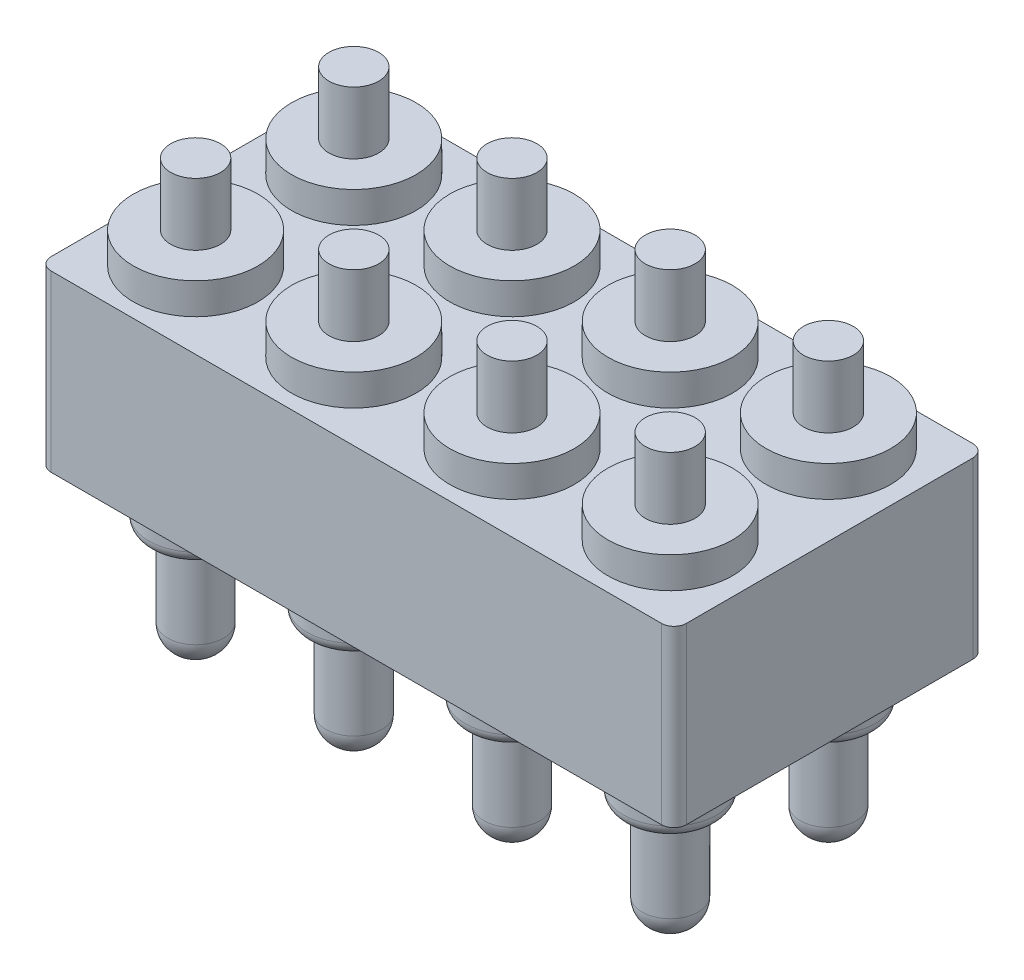
from build123d import *

# Parameters (mm, degrees)
SKETCH_1_W      = 10.2
SKETCH_1_H      = 5
EXTRUDE_1_DEPTH = 2.8
SKETCH_2_R      = 0.75
EXTRUDE_2_DEPTH = 3.65
SKETCH_3_R      = 1
EXTRUDE_3_DEPTH = 0.5
SKETCH_4_R      = 0.4
EXTRUDE_4_DEPTH = 1
SKETCH_5_R      = 0.45
EXTRUDE_5_DEPTH = 1.7
FILLET_1_R      = 0.2
FILLET_2_R      = 0.4
FILLET_3_R      = 0.2


with BuildPart() as part:
    # 草图1 → 凸台-拉伸1 (new body)
    with BuildSketch(Plane(origin=(0, 0, 0), x_dir=(1, 0, 0), z_dir=(0, 1, 0))):
        with Locations((5.1, 2.5)):
            Rectangle(SKETCH_1_W, SKETCH_1_H)
    extrude(amount=EXTRUDE_1_DEPTH)

    # 草图2 → 凸台-拉伸2 (add)
    with BuildSketch(Plane(origin=(0, 2.8, 0), x_dir=(1, 0, 0), z_dir=(0, 1, 0))):
        with Locations((1.29, 3.77)):
            Circle(SKETCH_2_R)
        with Locations((3.83, 3.77)):
            Circle(SKETCH_2_R)
        with Locations((6.37, 3.77)):
            Circle(SKETCH_2_R)
        with Locations((8.91, 3.77)):
            Circle(SKETCH_2_R)
        with Locations((3.83, 1.23)):
            Circle(SKETCH_2_R)
        with Locations((6.37, 1.23)):
            Circle(SKETCH_2_R)
        with Locations((8.91, 1.23)):
            Circle(SKETCH_2_R)
        with Locations((1.29, 1.23)):
            Circle(SKETCH_2_R)
    extrude(amount=-EXTRUDE_2_DEPTH)

    # 草图3 → 凸台-拉伸3 (add)
    with BuildSketch(Plane(origin=(0, 2.8, 0), x_dir=(1, 0, 0), z_dir=(0, 1, 0))):
        with Locations((1.29, 3.77)):
            Circle(SKETCH_3_R)
        with Locations((3.83, 3.77)):
            Circle(SKETCH_3_R)
        with Locations((6.37, 3.77)):
            Circle(SKETCH_3_R)
        with Locations((8.91, 3.77)):
            Circle(SKETCH_3_R)
        with Locations((3.83, 1.23)):
            Circle(SKETCH_3_R)
        with Locations((6.37, 1.23)):
            Circle(SKETCH_3_R)
        with Locations((8.91, 1.23)):
            Circle(SKETCH_3_R)
        with Locations((1.29, 1.23)):
            Circle(SKETCH_3_R)
    extrude(amount=EXTRUDE_3_DEPTH)

    # 草图4 → 凸台-拉伸4 (add)
    with BuildSketch(Plane(origin=(0, 3.3, 0), x_dir=(1, 0, 0), z_dir=(0, 1, 0))):
        with Locations((1.29, 1.23)):
            Circle(SKETCH_4_R)
        with Locations((3.83, 1.23)):
            Circle(SKETCH_4_R)
        with Locations((6.37, 1.23)):
            Circle(SKETCH_4_R)
        with Locations((8.91, 1.23)):
            Circle(SKETCH_4_R)
        with Locations((3.83, 3.77)):
            Circle(SKETCH_4_R)
        with Locations((6.37, 3.77)):
            Circle(SKETCH_4_R)
        with Locations((8.91, 3.77)):
            Circle(SKETCH_4_R)
        with Locations((1.29, 3.77)):
            Circle(SKETCH_4_R)
    extrude(amount=EXTRUDE_4_DEPTH)

    # 草图5 → 凸台-拉伸5 (add)
    with BuildSketch(Plane.XZ.offset(0.85)):
        with Locations((1.29, -3.77)):
            Circle(SKETCH_5_R)
        with Locations((3.83, -3.77)):
            Circle(SKETCH_5_R)
        with Locations((6.37, -3.77)):
            Circle(SKETCH_5_R)
        with Locations((8.91, -3.77)):
            Circle(SKETCH_5_R)
        with Locations((3.83, -1.23)):
            Circle(SKETCH_5_R)
        with Locations((6.37, -1.23)):
            Circle(SKETCH_5_R)
        with Locations((8.91, -1.23)):
            Circle(SKETCH_5_R)
        with Locations((1.29, -1.23)):
            Circle(SKETCH_5_R)
    extrude(amount=EXTRUDE_5_DEPTH)

    # 圆角1
    fillet_1_edges = [part.edges().sort_by_distance(p)[0] for p in [
        (0.54, -0.85, -3.77),
        (3.08, -0.85, -3.77),
        (5.62, -0.85, -3.77),
        (8.16, -0.85, -3.77),
        (3.08, -0.85, -1.23),
        (5.62, -0.85, -1.23),
        (8.16, -0.85, -1.23),
        (0.54, -0.85, -1.23),
    ]]
    fillet(fillet_1_edges, radius=FILLET_1_R)

    # 圆角2
    fillet_2_edges = [part.edges().sort_by_distance(p)[0] for p in [
        (0.84, -2.55, -3.77),
        (3.38, -2.55, -3.77),
        (5.92, -2.55, -3.77),
        (8.46, -2.55, -3.77),
        (3.38, -2.55, -1.23),
        (5.92, -2.55, -1.23),
        (8.46, -2.55, -1.23),
        (0.84, -2.55, -1.23),
    ]]
    fillet(fillet_2_edges, radius=FILLET_2_R)

    # 圆角3
    fillet_3_edges = [part.edges().sort_by_distance(p)[0] for p in [
        (0, 1.4, -5),
        (10.2, 1.4, -5),
        (10.2, 1.4, 0),
        (0, 1.4, 0),
    ]]
    fillet(fillet_3_edges, radius=FILLET_3_R)


solid = part.part
